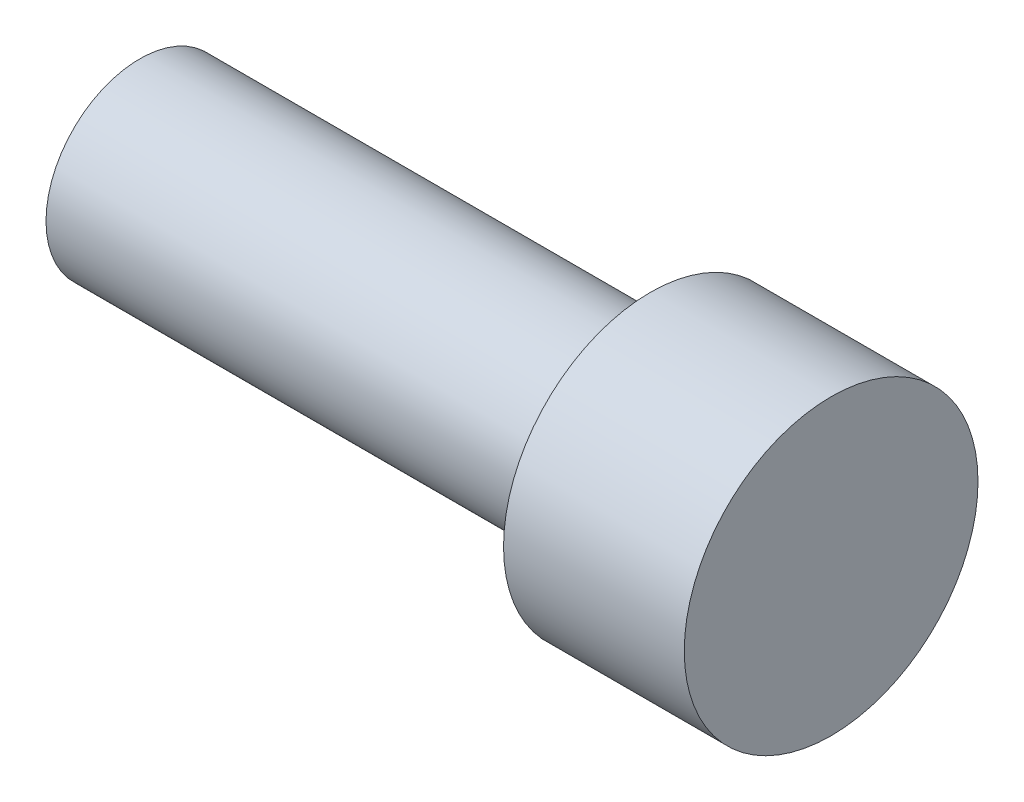
from build123d import *

# Parameters (mm, degrees)
SKETCH1_R           = 2.075
BOSS_EXTRUDE1_DEPTH = 11.3
SKETCH2_R           = 3.25
BOSS_EXTRUDE2_DEPTH = 4


with BuildPart() as part:
    # Sketch1 → Boss-Extrude1 (new body)
    with BuildSketch(Plane(origin=(0, 0, 0), x_dir=(0, 0, -1), z_dir=(1, 0, 0))):
        Circle(SKETCH1_R)
    extrude(amount=BOSS_EXTRUDE1_DEPTH)

    # Sketch2 → Boss-Extrude2 (add)
    with BuildSketch(Plane(origin=(11.3, 0, 0), x_dir=(0, 0, -1), z_dir=(1, 0, 0))):
        Circle(SKETCH2_R)
    extrude(amount=BOSS_EXTRUDE2_DEPTH)


solid = part.part
